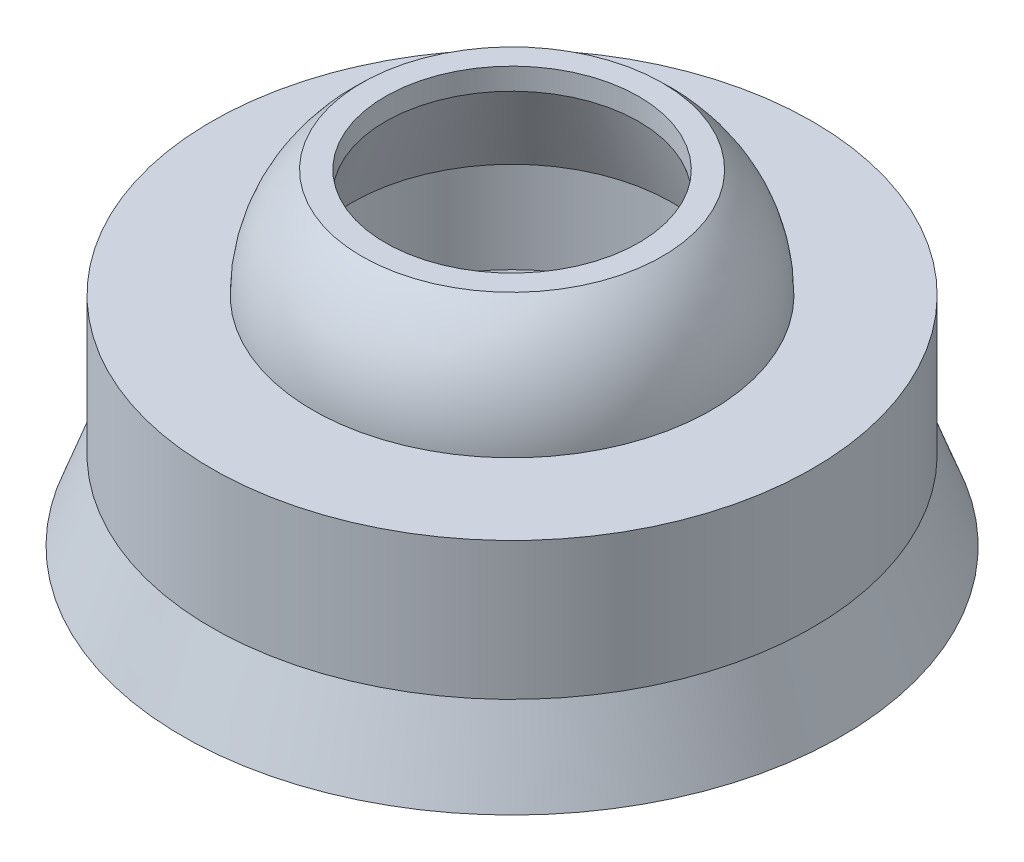
from build123d import *


with BuildPart() as part:
    # Sketch2 → Revolve1 (revolve)
    with BuildSketch(Plane(origin=(0, 0, 0), x_dir=(0, 0, -1), z_dir=(1, 0, 0))):
        with BuildLine():
            Line((-4.15, -1.9), (-4.15, 0))
            Line((-4.15, 0), (-2.752124344, 0))
            ThreePointArc((-2.752124344, 0), (-2.575, 0.822875656), (-2.075, 1.5))
            Line((-2.075, 1.5), (-1.75, 1.5))
            Line((-1.75, 1.5), (-1.75, 1.2))
            Line((-1.75, 1.2), (-2.211946903, 0))
            Line((-2.211946903, 0), (-2.211946903, -1.26))
            Line((-2.211946903, -1.26), (-1.75, -2.13))
            Line((-1.75, -2.13), (-2.25, -2.63))
            Line((-2.25, -2.63), (-2.85, -1.5))
            Line((-2.85, -1.5), (-3.3, -1.5))
            Line((-3.3, -1.5), (-3.85, -3))
            Line((-3.85, -3), (-4.55, -3))
            Line((-4.55, -3), (-4.15, -1.9))
        make_face()
    revolve(axis=Axis((0, 0, 0), (0, 1, 0)))


solid = part.part
